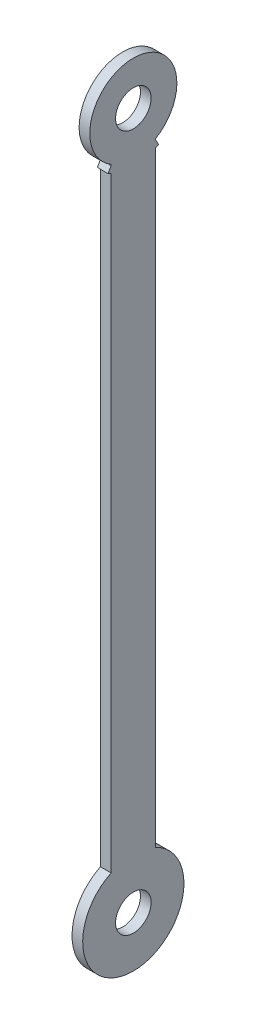
from build123d import *

# Parameters (mm, degrees)
BOSS_EXTRUDE1_DEPTH = 3
SKETCH2_R           = 10
CUT_EXTRUDE1_DEPTH  = 7


with BuildPart() as part:
    # Sketch1 → Boss-Extrude1 (new body, symmetric)
    with BuildSketch(Plane(origin=(0, 0, 0), x_dir=(0, 0, -1), z_dir=(1, 0, 0))):
        with BuildLine():
            ThreePointArc((-12.5, -170.38750305), (0, -224.5), (12.5, -170.38750305))
            Line((12.5, -170.38750305), (12.5, 170.38750305))
            ThreePointArc((12.5, 170.38750305), (13.38309417, 170.837671204), (14.25, 171.318275992))
            Line((14.25, 171.318275992), (12.5, 174.349364905))
            Line((12.5, 174.349364905), (12.5, 174.928692494))
            ThreePointArc((12.5, 174.928692494), (0, 220.5), (-12.5, 174.928692494))
            Line((-12.5, 174.928692494), (-12.5, 174.349364905))
            Line((-12.5, 174.349364905), (-14.25, 171.318275992))
            ThreePointArc((-14.25, 171.318275992), (-13.38309417, 170.837671204), (-12.5, 170.38750305))
            Line((-12.5, 170.38750305), (-12.5, -170.38750305))
        make_face()
    extrude(amount=BOSS_EXTRUDE1_DEPTH, both=True)

    # Sketch2 → Cut-Extrude1 (cut, through all)
    with BuildSketch(Plane(origin=(3, 0, 0), x_dir=(0, 0, -1), z_dir=(1, 0, 0))):
        with Locations((0, -196)):
            Circle(SKETCH2_R)
        with Locations((0, 196)):
            Circle(SKETCH2_R)
    extrude(amount=-CUT_EXTRUDE1_DEPTH, mode=Mode.SUBTRACT)


solid = part.part
